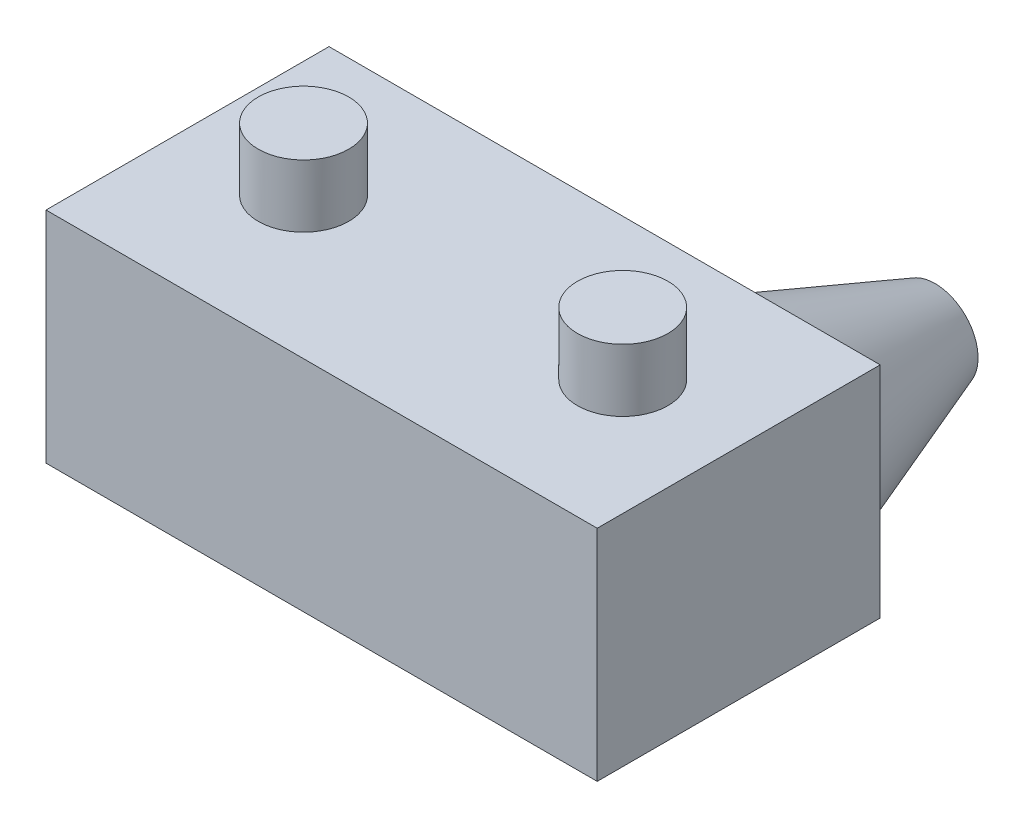
from build123d import *

# Parameters (mm, degrees)
SKETCH1_W           = 13.4
SKETCH1_H           = 5.33
BOSS_EXTRUDE1_DEPTH = 6.88
SKETCH2_R           = 1.1
BOSS_EXTRUDE2_DEPTH = 1.52
SKETCH3_R           = 2.5
BOSS_EXTRUDE3_DEPTH = 4
BOSS_EXTRUDE3_TAPER = 20


with BuildPart() as part:
    # Sketch1 → Boss-Extrude1 (new body)
    with BuildSketch(Plane.XY):
        with Locations((-6.7, 2.665)):
            Rectangle(SKETCH1_W, SKETCH1_H)
    extrude(amount=BOSS_EXTRUDE1_DEPTH)

    # Sketch2 → Boss-Extrude2 (add)
    with BuildSketch(Plane(origin=(0, 5.33, 0), x_dir=(1, 0, 0), z_dir=(0, 1, 0))):
        with Locations((-10.58, -3.44)):
            Circle(SKETCH2_R)
        with Locations((-2.82, -3.44)):
            Circle(SKETCH2_R)
    extrude(amount=BOSS_EXTRUDE2_DEPTH)

    # Sketch3 → Boss-Extrude3 (add)
    with BuildSketch(Plane(origin=(0, 0, 0), x_dir=(-1, 0, 0), z_dir=(0, 0, -1))):
        with Locations((2.665, 2.665)):
            Circle(SKETCH3_R)
    extrude(amount=BOSS_EXTRUDE3_DEPTH, taper=BOSS_EXTRUDE3_TAPER)


solid = part.part
